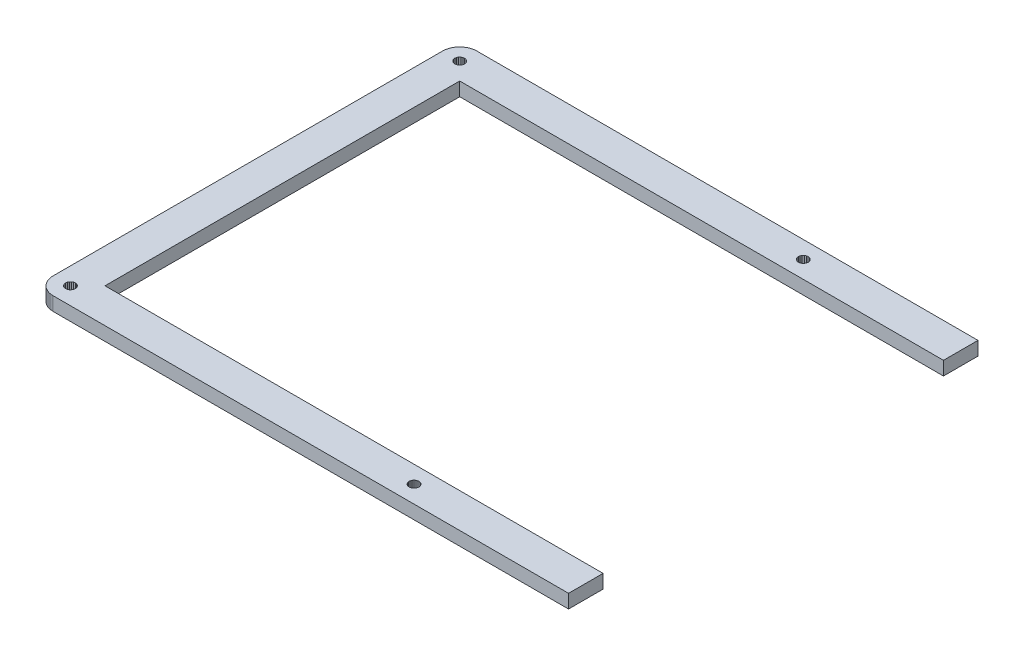
from build123d import *

# Parameters (mm, degrees)
BOSS_EXTRUDE2_DEPTH = 4.7625
CUT_EXTRUDE2_DEPTH  = 4.7625
SKETCH3_W           = 5
SKETCH3_H           = 4.7625
CUT_EXTRUDE3_DEPTH  = 4.7625


with BuildPart() as part:
    # Sketch1 → Boss-Extrude2 (new body)
    with BuildSketch(Plane(origin=(0, 0, 0), x_dir=(1, 0, 0), z_dir=(0, 1, 0))):
        Polygon((185.950525, 135.919), (185.950525, 147.9675), (6.09505, 147.968), (5.62377, 147.949), (5.15525, 147.894), (4.6936, 147.803), (4.24021, 147.675), (3.79786, 147.511), (3.37068, 147.314), (2.96003, 147.085), (2.56728, 146.822), (2.19797, 146.529), (1.85208, 146.21), (1.53238, 145.865), (1.24024, 145.495), (0.978408, 145.102), (0.748273, 144.691), (0.551215, 144.264), (0.38723, 143.822), (0.259071, 143.368), (0.168121, 142.907), (0.112999, 142.44), (0.0950846, 141.967), (0.0937066, 6.0923), (0.112999, 5.62102), (0.168121, 5.15387), (0.259071, 4.69085), (0.38723, 4.23746), (0.551215, 3.79511), (0.748273, 3.36793), (0.978408, 2.95727), (1.24024, 2.56453), (1.53238, 2.19659), (1.85208, 1.84933), (2.19797, 1.52962), (2.56728, 1.23748), (2.96003, 0.975653), (3.37068, 0.745518), (3.79786, 0.549836), (4.24021, 0.385851), (4.6936, 0.257693), (5.15525, 0.165365), (5.62377, 0.110243), (6.09505, 0.0909507), (185.950525, 0.0909507), (185.950525, 12.1405), (12.1447, 12.1405), (12.1447, 135.919), align=None)
        Polygon((5.10565, 7.5117), (5.58518, 7.75698), (6.11851, 7.84105), (6.65318, 7.75698), (7.13274, 7.5117), (7.51445, 7.12996), (7.75974, 6.65043), (7.8438, 6.11572), (7.75974, 5.5838), (7.51445, 5.10286), (7.13274, 4.72115), (6.65318, 4.47587), (6.11851, 4.3918), (5.58518, 4.47587), (5.10565, 4.72115), (4.72391, 5.10286), (4.47862, 5.5838), (4.39318, 6.11572), (4.47862, 6.65043), (4.72391, 7.12996), align=None, mode=Mode.SUBTRACT)
        Polygon((124.992, 7.5117), (125.473, 7.75698), (126.007, 7.84105), (126.54, 7.75698), (127.021, 7.5117), (127.403, 7.12996), (127.648, 6.65043), (127.732, 6.11572), (127.648, 5.5838), (127.403, 5.10286), (127.021, 4.72115), (126.54, 4.47587), (126.007, 4.3918), (125.473, 4.47587), (124.992, 4.72115), (124.612, 5.10286), (124.365, 5.5838), (124.281, 6.11572), (124.365, 6.65043), (124.612, 7.12996), align=None, mode=Mode.SUBTRACT)
        Polygon((5.10565, 143.338), (5.58518, 143.583), (6.11851, 143.667), (6.65318, 143.583), (7.13274, 143.338), (7.51445, 142.956), (7.75974, 142.477), (7.8438, 141.942), (7.75974, 141.409), (7.51445, 140.929), (7.13274, 140.547), (6.65318, 140.302), (6.11851, 140.217), (5.58518, 140.302), (5.10565, 140.547), (4.72391, 140.929), (4.47862, 141.409), (4.39318, 141.942), (4.47862, 142.477), (4.72391, 142.956), align=None, mode=Mode.SUBTRACT)
        Polygon((124.992, 143.338), (125.473, 143.583), (126.007, 143.667), (126.54, 143.583), (127.021, 143.338), (127.403, 142.956), (127.648, 142.477), (127.732, 141.942), (127.648, 141.409), (127.403, 140.929), (127.021, 140.547), (126.54, 140.302), (126.007, 140.217), (125.473, 140.302), (124.992, 140.547), (124.612, 140.929), (124.365, 141.409), (124.281, 141.942), (124.365, 142.477), (124.612, 142.956), align=None, mode=Mode.SUBTRACT)
    extrude(amount=BOSS_EXTRUDE2_DEPTH)

    # Sketch2 → Cut-Extrude2 (cut)
    with BuildSketch(Plane(origin=(0, 4.7625, 0), x_dir=(1, 0, 0), z_dir=(0, 1, 0))):
        Polygon((180.950525, 141.94325), (180.950525, 147.9675), (185.950525, 147.9675), (185.950525, 141.94325), (185.950525, 135.919), (180.950525, 135.919), align=None)
    extrude(amount=-CUT_EXTRUDE2_DEPTH, mode=Mode.SUBTRACT)

    # Sketch3 → Cut-Extrude3 (cut)
    with BuildSketch(Plane.XY.offset(-147.9675)):
        with Locations((183.450525, 2.38125)):
            Rectangle(SKETCH3_W, SKETCH3_H)
    extrude(amount=-CUT_EXTRUDE3_DEPTH, mode=Mode.SUBTRACT)


solid = part.part
